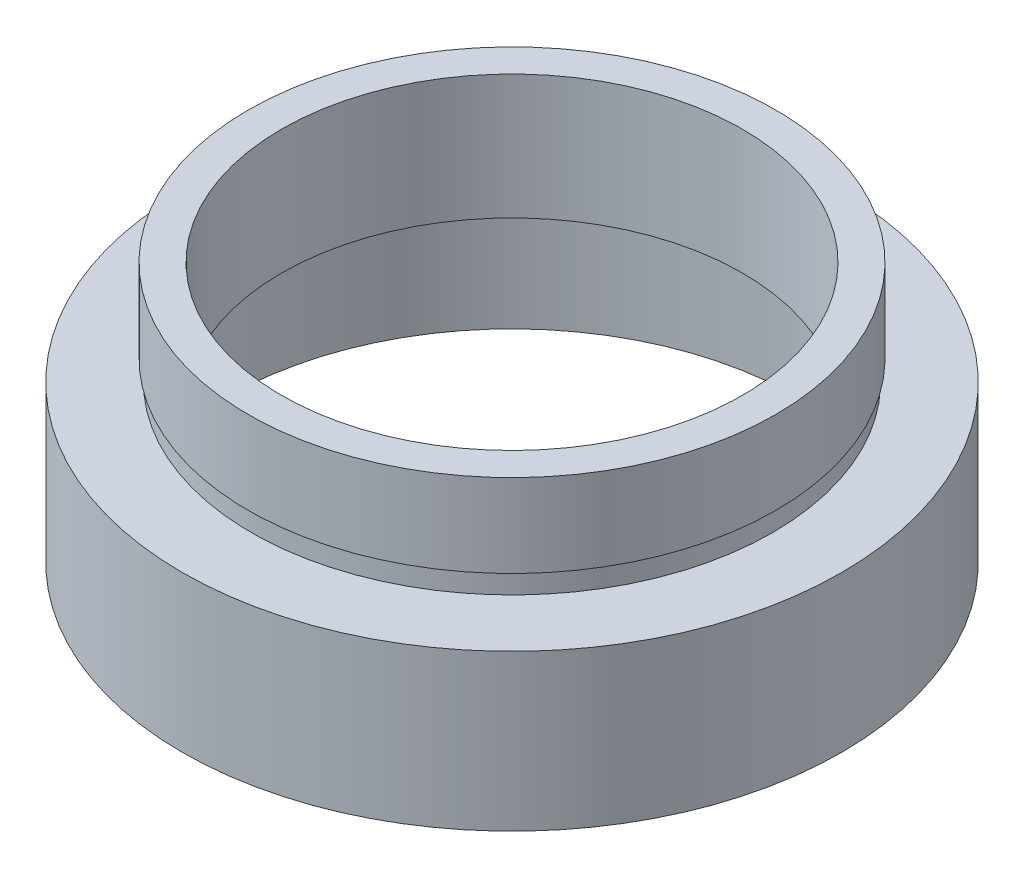
from build123d import *


with BuildPart() as part:
    # 草图1 → 旋转1 (revolve)
    with BuildSketch(Plane.XY, mode=Mode.PRIVATE) as revolve_1_sk:
        Polygon((13.75, 0), (13.75, 5.5), (14.35, 5.5), (14.35, 6.5), (11.1, 6.5), (11.1, 12.5), (12.7, 12.5), (12.7, 8.5), (12.55, 8.5), (12.55, 7.5), (15.875, 7.5), (15.875, 0), align=None)
    revolve(revolve_1_sk.sketch.rotate(Axis((0, 16.886018237, 0), (0, -1, 0)), 180), axis=Axis((0, 16.886018237, 0), (0, -1, 0)))  # turned: the seam where the file's is


solid = part.part
